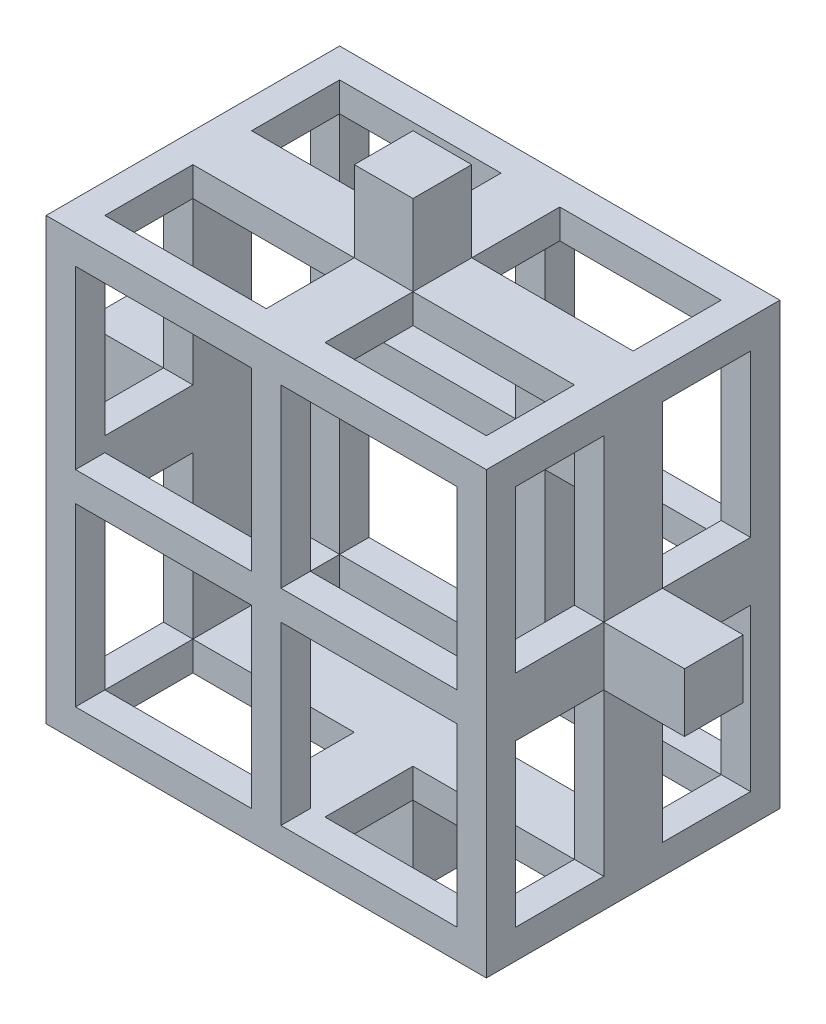
from build123d import *

# Parameters (mm, degrees)
SKETCH_1_W               = 15
SKETCH_1_H               = 15
SKETCH_1_W_2             = 6
SKETCH_1_H_2             = 6
SKETCH_1_W_3             = 2
SKETCH_1_H_3             = 2.75
SKETCH_1_W_4             = 2.75
SKETCH_1_H_4             = 2
EXTRUDE_1_DEPTH          = 10
SKETCH_2_W               = 2
SKETCH_2_H               = 4
CUT_EXTRUDE_1_DEPTH      = 2.75
SKETCH_3_W               = 4
SKETCH_3_H               = 2
CUT_EXTRUDE_2_DEPTH      = 2.75
SKETCH_4_W               = 2
SKETCH_4_H               = 4
CUT_EXTRUDE_3_DEPTH      = 2.75
SKETCH_5_W               = 4
SKETCH_5_H               = 2
CUT_EXTRUDE_4_DEPTH      = 2.75
SKETCH_6_W               = 5.5
SKETCH_6_H               = 3
CUT_EXTRUDE_5_DEPTH      = 18.75
SKETCH_7_W               = 3
SKETCH_7_H               = 5.5
CUT_EXTRUDE_6_DEPTH      = 18.75
SKETCH_8_W               = 8
SKETCH_8_H               = 13
CUT_EXTRUDE_7_DEPTH      = 6
CUT_EXTRUDE_7_DEPTH_BACK = 0.75
SKETCH_9_W               = 8
SKETCH_9_H               = 13
CUT_EXTRUDE_8_DEPTH      = 6
SKETCH_10_W              = 8
SKETCH_10_H              = 13
CUT_EXTRUDE_9_DEPTH      = 6


with BuildPart() as part:
    # ｽｹｯﾁ1 → ﾎﾞｽ - 押し出し1 (new body)
    with BuildSketch(Plane.XY):
        with Locations((-13.66786655, 0.754091784)):
            Rectangle(SKETCH_1_W, SKETCH_1_H)
        with Locations((-17.16786655, -2.745908216)):
            Rectangle(SKETCH_1_W_2, SKETCH_1_H_2, mode=Mode.SUBTRACT)
        with Locations((-10.16786655, -2.745908216)):
            Rectangle(SKETCH_1_W_2, SKETCH_1_H_2, mode=Mode.SUBTRACT)
        with Locations((-10.16786655, 4.254091784)):
            Rectangle(SKETCH_1_W_2, SKETCH_1_H_2, mode=Mode.SUBTRACT)
        with Locations((-17.16786655, 4.254091784)):
            Rectangle(SKETCH_1_W_2, SKETCH_1_H_2, mode=Mode.SUBTRACT)
        with Locations((-13.66786655, 9.629091784)):
            Rectangle(SKETCH_1_W_3, SKETCH_1_H_3)
        with Locations((-22.54286655, 0.754091784)):
            Rectangle(SKETCH_1_W_4, SKETCH_1_H_4)
        with Locations((-4.79286655, 0.754091784)):
            Rectangle(SKETCH_1_W_4, SKETCH_1_H_4)
        with Locations((-13.66786655, -8.120908216)):
            Rectangle(SKETCH_1_W_3, SKETCH_1_H_3)
    extrude(amount=EXTRUDE_1_DEPTH)

    # ｽｹｯﾁ2 → ｶｯﾄ - 押し出し1 (cut)
    with BuildSketch(Plane(origin=(0, 11.004091784, 0), x_dir=(1, 0, 0), z_dir=(0, 1, 0))):
        with Locations((-13.66786655, -2)):
            Rectangle(SKETCH_2_W, SKETCH_2_H)
        with Locations((-13.66786655, -8)):
            Rectangle(SKETCH_2_W, SKETCH_2_H)
    extrude(amount=-CUT_EXTRUDE_1_DEPTH, mode=Mode.SUBTRACT)

    # ｽｹｯﾁ3 → ｶｯﾄ - 押し出し2 (cut)
    with BuildSketch(Plane(origin=(-3.41786655, 0, 0), x_dir=(0, 0, -1), z_dir=(1, 0, 0))):
        with Locations((-8, 0.754091784)):
            Rectangle(SKETCH_3_W, SKETCH_3_H)
        with Locations((-2, 0.754091784)):
            Rectangle(SKETCH_3_W, SKETCH_3_H)
    extrude(amount=-CUT_EXTRUDE_2_DEPTH, mode=Mode.SUBTRACT)

    # ｽｹｯﾁ4 → ｶｯﾄ - 押し出し3 (cut)
    with BuildSketch(Plane.XZ.offset(9.495908216)):
        with Locations((-13.66786655, 8)):
            Rectangle(SKETCH_4_W, SKETCH_4_H)
        with Locations((-13.66786655, 2)):
            Rectangle(SKETCH_4_W, SKETCH_4_H)
    extrude(amount=-CUT_EXTRUDE_3_DEPTH, mode=Mode.SUBTRACT)

    # ｽｹｯﾁ5 → ｶｯﾄ - 押し出し4 (cut)
    with BuildSketch(Plane.ZY.offset(23.91786655)):
        with Locations((2, 0.754091784)):
            Rectangle(SKETCH_5_W, SKETCH_5_H)
        with Locations((8, 0.754091784)):
            Rectangle(SKETCH_5_W, SKETCH_5_H)
    extrude(amount=-CUT_EXTRUDE_4_DEPTH, mode=Mode.SUBTRACT)

    # ｽｹｯﾁ6 → ｶｯﾄ - 押し出し5 (cut, through all)
    with BuildSketch(Plane(origin=(0, 8.254091784, 0), x_dir=(1, 0, 0), z_dir=(0, 1, 0))):
        with Locations((-17.41786655, -2.5)):
            Rectangle(SKETCH_6_W, SKETCH_6_H)
        with Locations((-9.91786655, -2.5)):
            Rectangle(SKETCH_6_W, SKETCH_6_H)
        with Locations((-17.41786655, -7.5)):
            Rectangle(SKETCH_6_W, SKETCH_6_H)
        with Locations((-9.91786655, -7.5)):
            Rectangle(SKETCH_6_W, SKETCH_6_H)
    extrude(amount=-CUT_EXTRUDE_5_DEPTH, mode=Mode.SUBTRACT)

    # ｽｹｯﾁ7 → ｶｯﾄ - 押し出し6 (cut, through all)
    with BuildSketch(Plane(origin=(-6.16786655, 0, 0), x_dir=(0, 0, -1), z_dir=(1, 0, 0))):
        with Locations((-7.5, 4.504091784)):
            Rectangle(SKETCH_7_W, SKETCH_7_H)
        with Locations((-2.5, 4.504091784)):
            Rectangle(SKETCH_7_W, SKETCH_7_H)
        with Locations((-7.5, -2.995908216)):
            Rectangle(SKETCH_7_W, SKETCH_7_H)
        with Locations((-2.5, -2.995908216)):
            Rectangle(SKETCH_7_W, SKETCH_7_H)
    extrude(amount=-CUT_EXTRUDE_6_DEPTH, mode=Mode.SUBTRACT)

    # ｽｹｯﾁ8 → ｶｯﾄ - 押し出し7 (cut, two sides)
    with BuildSketch(Plane.ZY.offset(14.16786655)) as cut_extrude_7_sk:
        with Locations((5, 0.754091784)):
            Rectangle(SKETCH_8_W, SKETCH_8_H)
    extrude(amount=CUT_EXTRUDE_7_DEPTH, mode=Mode.SUBTRACT)
    extrude(cut_extrude_7_sk.sketch, amount=-CUT_EXTRUDE_7_DEPTH_BACK, mode=Mode.SUBTRACT)

    # ｽｹｯﾁ9 → ｶｯﾄ - 押し出し8 (cut)
    with BuildSketch(Plane(origin=(-13.16786655, 0, 0), x_dir=(0, 0, -1), z_dir=(1, 0, 0))):
        with Locations((-5, 0.754091784)):
            Rectangle(SKETCH_9_W, SKETCH_9_H)
    extrude(amount=CUT_EXTRUDE_8_DEPTH, mode=Mode.SUBTRACT)

    # ｽｹｯﾁ10 → ｶｯﾄ - 押し出し9 (cut)
    with BuildSketch(Plane(origin=(-13.16786655, 0, 0), x_dir=(0, 0, -1), z_dir=(1, 0, 0))):
        with Locations((-5, 0.754091784)):
            Rectangle(SKETCH_10_W, SKETCH_10_H)
    extrude(amount=-CUT_EXTRUDE_9_DEPTH, mode=Mode.SUBTRACT)


solid = part.part
